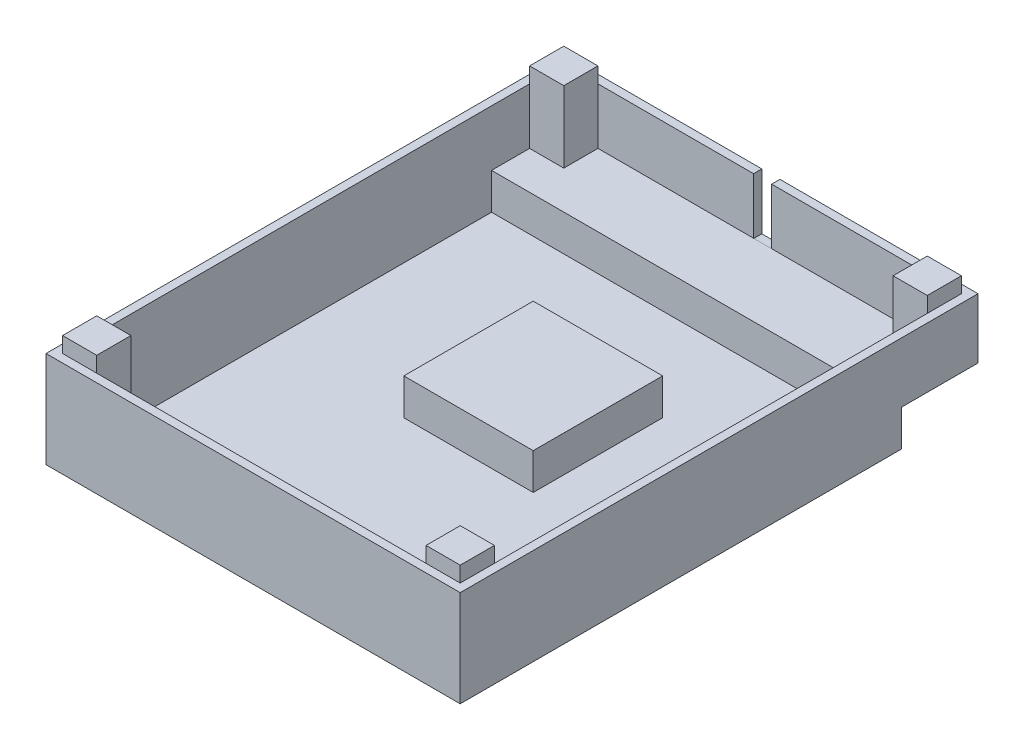
from build123d import *

# Parameters (mm, degrees)
SKETCH5_W           = 100
SKETCH5_H           = 11.6
BOSS_EXTRUDE3_DEPTH = 80
SKETCH6_W           = 85.25
SKETCH6_H           = 7
BOSS_EXTRUDE4_DEPTH = 80
SKETCH7_W           = 76.8
SKETCH7_H           = 96.8
CUT_EXTRUDE1_DEPTH  = 10.8
SKETCH8_W           = 76.8
SKETCH8_H           = 82.85
CUT_EXTRUDE2_DEPTH  = 7
SKETCH10_W          = 6.6
SKETCH10_H          = 6.6
BOSS_EXTRUDE5_DEPTH = 17.8
SKETCH12_W          = 6.6
SKETCH12_H          = 6.6
BOSS_EXTRUDE6_DEPTH = 10.8
SKETCH15_W          = 3.5
SKETCH15_H          = 10.858624792
CUT_EXTRUDE4_DEPTH  = 1.6
SKETCH16_W          = 6.6
SKETCH16_H          = 6.6
BOSS_EXTRUDE8_DEPTH = 3
SKETCH18_W          = 25
SKETCH18_H          = 25
BOSS_EXTRUDE9_DEPTH = 7
SKETCH19_W          = 4.5
SKETCH19_H          = 6
SKETCH19_W_2        = 6
SKETCH19_H_2        = 5.5
CUT_EXTRUDE5_DEPTH  = 6.2


with BuildPart() as part:
    # Sketch5 → Boss-Extrude3 (new body)
    with BuildSketch(Plane(origin=(0, 0, 0), x_dir=(0, 0, -1), z_dir=(1, 0, 0))):
        with Locations((50, 5.8)):
            Rectangle(SKETCH5_W, SKETCH5_H)
    extrude(amount=BOSS_EXTRUDE3_DEPTH)

    # Sketch7 → Cut-Extrude1 (cut)
    with BuildSketch(Plane(origin=(0, 11.6, 0), x_dir=(1, 0, 0), z_dir=(0, 1, 0))):
        with Locations((40, 50)):
            Rectangle(SKETCH7_W, SKETCH7_H)
    extrude(amount=-CUT_EXTRUDE1_DEPTH, mode=Mode.SUBTRACT)


with BuildPart() as body_2:
    # Sketch6 → Boss-Extrude4 (new body)
    with BuildSketch(Plane(origin=(80, 0, 0), x_dir=(0, 0, -1), z_dir=(1, 0, 0))):
        with Locations((42.625, -3.5)):
            Rectangle(SKETCH6_W, SKETCH6_H)
    extrude(amount=-BOSS_EXTRUDE4_DEPTH)


with BuildPart() as cut_extrude2_tool:
    # Sketch8 → Cut-Extrude2 (new body)
    with BuildSketch(Plane(origin=(0, 0.8, 0), x_dir=(1, 0, 0), z_dir=(0, 1, 0))):
        with Locations((40, 43.025)):
            Rectangle(SKETCH8_W, SKETCH8_H)
    extrude(amount=-CUT_EXTRUDE2_DEPTH)


with BuildPart() as part_1:
    add(part.part)

    # Cut-Extrude2: cut by cut_extrude2_tool
    add(cut_extrude2_tool.part, mode=Mode.SUBTRACT)



with BuildPart() as body_2_1:
    add(body_2.part)

    # Cut-Extrude2: cut by cut_extrude2_tool
    add(cut_extrude2_tool.part, mode=Mode.SUBTRACT)


with BuildPart() as part_2:
    add(part_1.part)

    add(body_2_1.part)  # Boss-Extrude5 merges body 2
    # Sketch10 → Boss-Extrude5 (add)
    with BuildSketch(Plane(origin=(0, -6.2, 0), x_dir=(1, 0, 0), z_dir=(0, 1, 0))):
        with Locations((4.9, 4.9)):
            Rectangle(SKETCH10_W, SKETCH10_H)
        with Locations((75.1, 4.9)):
            Rectangle(SKETCH10_W, SKETCH10_H)
    extrude(amount=BOSS_EXTRUDE5_DEPTH)

    # Sketch12 → Boss-Extrude6 (add)
    with BuildSketch(Plane(origin=(0, 0.8, 0), x_dir=(1, 0, 0), z_dir=(0, 1, 0))):
        with Locations((4.9, 95.1)):
            Rectangle(SKETCH12_W, SKETCH12_H)
        with Locations((75.1, 95.1)):
            Rectangle(SKETCH12_W, SKETCH12_H)
    extrude(amount=BOSS_EXTRUDE6_DEPTH)

    # Sketch15 → Cut-Extrude4 (cut)
    with BuildSketch(Plane(origin=(0, 0, -100), x_dir=(-1, 0, 0), z_dir=(0, 0, -1))):
        with Locations((-40, 6.170687604)):
            Rectangle(SKETCH15_W, SKETCH15_H)
    extrude(amount=-CUT_EXTRUDE4_DEPTH, mode=Mode.SUBTRACT)

    # Sketch16 → Boss-Extrude8 (add)
    with BuildSketch(Plane(origin=(0, 11.6, 0), x_dir=(1, 0, 0), z_dir=(0, 1, 0))):
        with Locations((4.9, 95.1)):
            Rectangle(SKETCH16_W, SKETCH16_H)
        with Locations((75.1, 4.9)):
            Rectangle(SKETCH16_W, SKETCH16_H)
        with Locations((4.9, 4.9)):
            Rectangle(SKETCH16_W, SKETCH16_H)
        with Locations((75.1, 95.1)):
            Rectangle(SKETCH16_W, SKETCH16_H)
    extrude(amount=BOSS_EXTRUDE8_DEPTH)

    # Sketch18 → Boss-Extrude9 (add)
    with BuildSketch(Plane(origin=(0, -6.2, 0), x_dir=(1, 0, 0), z_dir=(0, 1, 0))):
        with Locations((40, 54.1)):
            Rectangle(SKETCH18_W, SKETCH18_H)
    extrude(amount=BOSS_EXTRUDE9_DEPTH)

    # Sketch19 → Cut-Extrude5 (cut)
    with BuildSketch(Plane.XZ.offset(7)):
        with Locations((34.75, -46.6)):
            Rectangle(SKETCH19_W, SKETCH19_H)
        with Locations((34.75, -61.6)):
            Rectangle(SKETCH19_W, SKETCH19_H)
        with Locations((45, -54.1)):
            Rectangle(SKETCH19_W_2, SKETCH19_H_2)
    extrude(amount=-CUT_EXTRUDE5_DEPTH, mode=Mode.SUBTRACT)


solid = part_2.part
